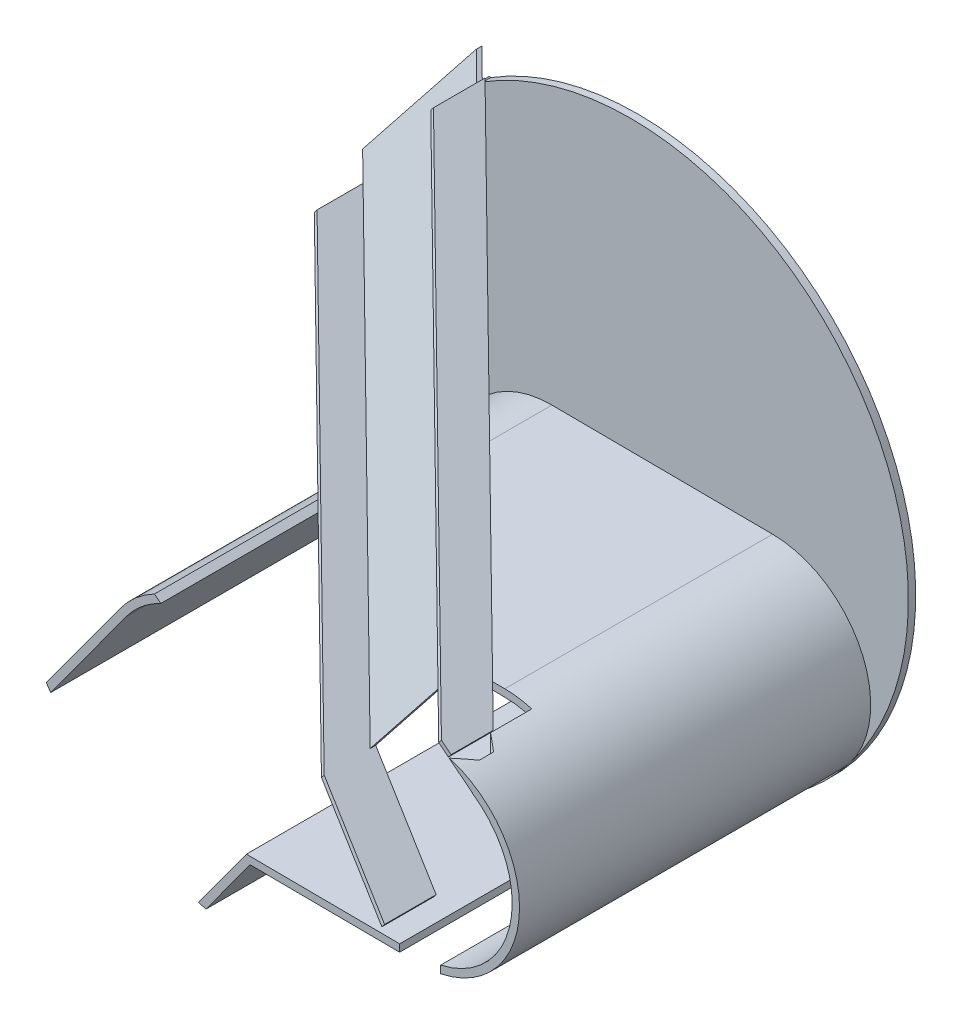
from build123d import *

# Parameters (mm, degrees)
BOSS_EXTRUDE1_DEPTH     = 5
BOSS_EXTRUDE2_DEPTH     = 240
CUT_EXTRUDE1_DEPTH      = 57
SKETCH5_W               = 28
SKETCH5_H               = 240
CUT_EXTRUDE2_DEPTH      = 2
CUT_EXTRUDE2_DEPTH_BACK = 10
BOSS_EXTRUDE3_DEPTH     = 3
BOSS_EXTRUDE8_DEPTH     = 125
BOSS_EXTRUDE9_DEPTH     = 3
CUT_EXTRUDE3_DEPTH      = 150


with BuildPart() as part:
    # Sketch1 → Boss-Extrude1 (new body)
    with BuildSketch(Plane.XY):
        with BuildLine():
            Line((-156.221589014, -108.14256852), (-104.600080398, -37.358665564))
            ThreePointArc((-104.600080398, -37.358665564), (-17.275313464, -23.688091466), (-3.604733957, -111.012857552))
            Line((-3.604733957, -111.012857552), (-55.226242573, -181.796760508))
            ThreePointArc((-55.226242573, -181.796760508), (188.36019605, 24.908563671), (-100.582828609, 161.192724988))
            Line((-100.582828609, 161.192724988), (-101.249092052, 161.721574551))
            Line((-101.249092052, 161.721574551), (-178.962550118, 63.815402961))
            ThreePointArc((-178.962550118, 63.815402961), (-188.359995143, -24.91008289), (-156.221589014, -108.14256852))
        make_face()
    extrude(amount=BOSS_EXTRUDE1_DEPTH)

    # Sketch2 → Boss-Extrude2 (add)
    with BuildSketch(Plane.XY.offset(5)):
        with BuildLine():
            Line((-53.682461639, -11.687175551), (97.122325749, -12.700480692))
            ThreePointArc((97.122325749, -12.700480692), (159.200967064, -75.619017647), (96.28243011, -137.697658962))
            Line((96.28243011, -137.697658962), (-22.483523352, -136.899632896))
            Line((-22.483523352, -136.899632896), (-55.226242573, -181.796760508))
            Line((-55.226242573, -181.796760508), (-50.113689849, -183.271978463))
            Line((-50.113689849, -183.271978463), (-19.954012463, -141.916742352))
            Line((-19.954012463, -141.916742352), (96.248834284, -142.697546092))
            ThreePointArc((96.248834284, -142.697546092), (164.200854195, -75.652613472), (97.155921575, -7.700593561))
            Line((97.155921575, -7.700593561), (-53.648865813, -6.68728842))
            ThreePointArc((-53.648865813, -6.68728842), (-84.490563822, -13.912967552), (-108.639893019, -34.412496189))
            Line((-108.639893019, -34.412496189), (-159.188664076, -103.725451215))
            ThreePointArc((-159.188664076, -103.725451215), (-157.720590507, -105.944397352), (-156.221589014, -108.14256852))
            Line((-156.221589014, -108.14256852), (-104.600079422, -37.358664226))
            ThreePointArc((-104.600079422, -37.358664226), (-82.239589425, -18.377619191), (-53.682461639, -11.687175551))
        make_face()
    extrude(amount=BOSS_EXTRUDE2_DEPTH)

    # Sketch3 → Cut-Extrude1 (cut)
    with BuildSketch(Plane.XY.offset(245)):
        with BuildLine():
            Line((-22.32861185, -18.477374243), (115.778336244, -19.405358579))
            ThreePointArc((115.778336244, -19.405358579), (124.443199044, -20.564624968), (132.543492936, -23.852327019))
            Line((132.543492936, -23.852327019), (115.590087785, -10.395486466))
            ThreePointArc((115.590087785, -10.395486466), (106.466425947, -8.409000458), (97.155921575, -7.700593561))
            Line((97.155921575, -7.700593561), (-53.648865813, -6.68728842))
            ThreePointArc((-53.648865813, -6.68728842), (-68.336249989, -8.203586912), (-82.342539109, -12.877159439))
            Line((-82.342539109, -12.877159439), (-77.164256517, -16.987444219))
            Line((-77.164256517, -16.987444219), (-22.32861185, -18.477374243))
        make_face()
    extrude(amount=-CUT_EXTRUDE1_DEPTH, mode=Mode.SUBTRACT)

    # Sketch5 → Cut-Extrude2 (cut, two sides)
    with BuildSketch(Plane(origin=(-0.920845541, -137.044519359, 0), x_dir=(0.999977426, -0.006719165, 0), z_dir=(0.006719165, 0.999977426, 0))) as cut_extrude2_sk:
        with Locations((97.206835425, -125)):
            Rectangle(SKETCH5_W, SKETCH5_H)
    extrude(amount=CUT_EXTRUDE2_DEPTH, mode=Mode.SUBTRACT)
    extrude(cut_extrude2_sk.sketch, amount=-CUT_EXTRUDE2_DEPTH_BACK, mode=Mode.SUBTRACT)

    # Sketch12 → Cut-Extrude3 (cut)
    with BuildSketch(Plane(origin=(-53.721281932, 42.641505871, 89.891408816), x_dir=(-0.879922716, -0.20363034, -0.42926763), z_dir=(0.475116842, -0.377126101, -0.795009365))):
        Polygon((-206.883720933, -112.273873862), (64.877277089, 159.058147248), (157.435069425, 66.354020706), (-136.195988802, -226.813538544), align=None)
    extrude(amount=-CUT_EXTRUDE3_DEPTH, mode=Mode.SUBTRACT)


with BuildPart() as body_2:
    # Sketch8 → Boss-Extrude3 (new body)
    with BuildSketch(Plane(origin=(39.615824932, 49.909421739, 0), x_dir=(0.783249373, -0.621707665, 0), z_dir=(-0.621707665, -0.783249373, 0))):
        Polygon((-179.846830256, 5), (59.99391493, 188), (96.998817362, 216.234973752), (96.998817362, 245), (88.539274328, 245), (59.99391493, 223.219710893), (-179.846830256, 40.219710893), align=None)
    extrude(amount=-BOSS_EXTRUDE3_DEPTH)


with BuildPart() as body_3:
    # Sketch9 → Boss-Extrude8 (new body)
    with BuildSketch(Plane(origin=(39.615824932, 49.909421739, 0), x_dir=(-0.783249373, 0.621707665, 0), z_dir=(0.621707665, 0.783249373, 0))):
        Polygon((-59.99391493, 191.773540453), (-59.99391493, 188), (194.432609905, -6.129041788), (194.432609905, -2.355501335), align=None)
    extrude(amount=-BOSS_EXTRUDE8_DEPTH)


with BuildPart() as body_4:
    # Sketch11 → Boss-Extrude9 (new body)
    with BuildSketch(Plane(origin=(-38.097633135, -47.996749851, 0), x_dir=(0.783249373, -0.621707665, 0), z_dir=(-0.621707665, -0.783249373, 0))):
        Polygon((-179.846830256, 5), (-179.846830256, 40.219710893), (59.99391493, 223.219710893), (137.623861395, 242.703985504), (137.623861395, 207.484274612), (59.99391493, 188), align=None)
    extrude(amount=BOSS_EXTRUDE9_DEPTH)


solid = Compound([part.part, body_2.part, body_3.part, body_4.part])
